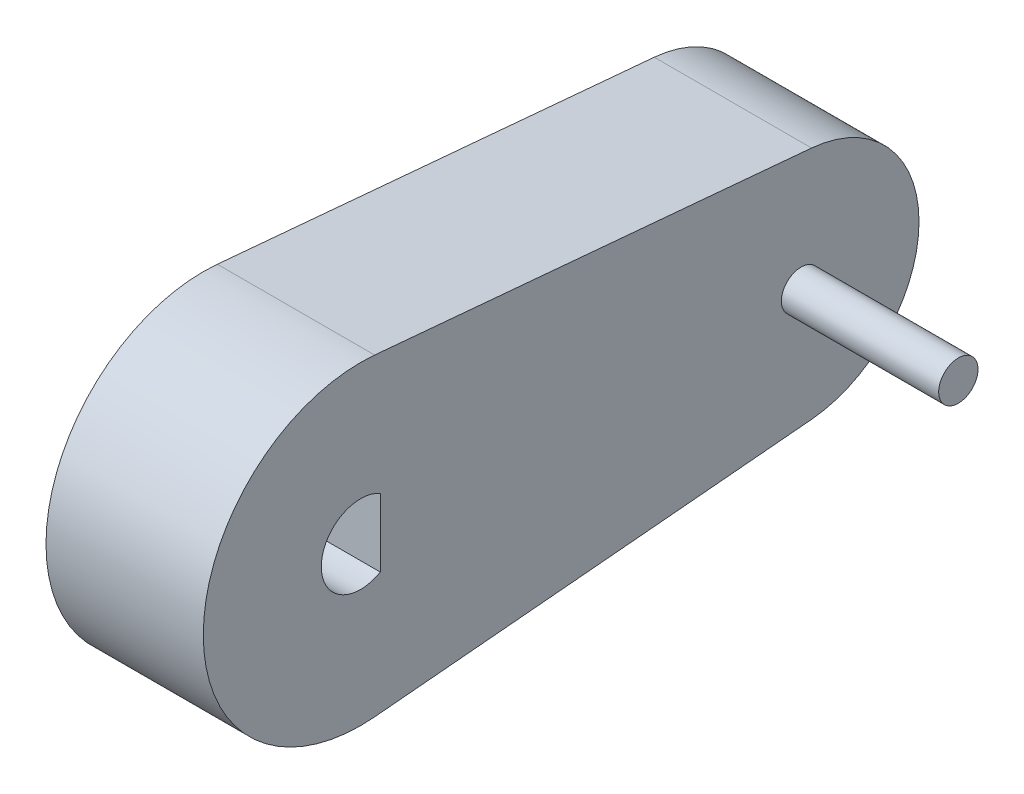
from build123d import *

# Parameters (mm, degrees)
BOSS_EXTRUDE1_DEPTH = 50.8
SKETCH2_R           = 6.35
BOSS_EXTRUDE2_DEPTH = 50.8


with BuildPart() as part:
    # Sketch1 → Boss-Extrude1 (new body)
    with BuildSketch(Plane(origin=(0, 0, 0), x_dir=(0, 0, -1), z_dir=(1, 0, 0))):
        with BuildLine():
            Line((4.535714286, 50.597107585), (145.641785714, 37.947830688))
            ThreePointArc((145.641785714, 37.947830688), (180.34, 0), (145.641785714, -37.947830688))
            Line((145.641785714, -37.947830688), (4.535714286, -50.597107585))
            ThreePointArc((4.535714286, -50.597107585), (-50.8, 0), (4.535714286, 50.597107585))
        make_face()
        with BuildLine():
            Line((6.35, 10.998522628), (6.35, -10.998522628))
            ThreePointArc((6.35, -10.998522628), (-12.7, 0), (6.35, 10.998522628))
        make_face(mode=Mode.SUBTRACT)
    extrude(amount=BOSS_EXTRUDE1_DEPTH)

    # Sketch2 → Boss-Extrude2 (add)
    with BuildSketch(Plane(origin=(50.8, 0, 0), x_dir=(0, 0, -1), z_dir=(1, 0, 0))):
        with Locations((142.24, 0)):
            Circle(SKETCH2_R)
    extrude(amount=BOSS_EXTRUDE2_DEPTH)


solid = part.part
